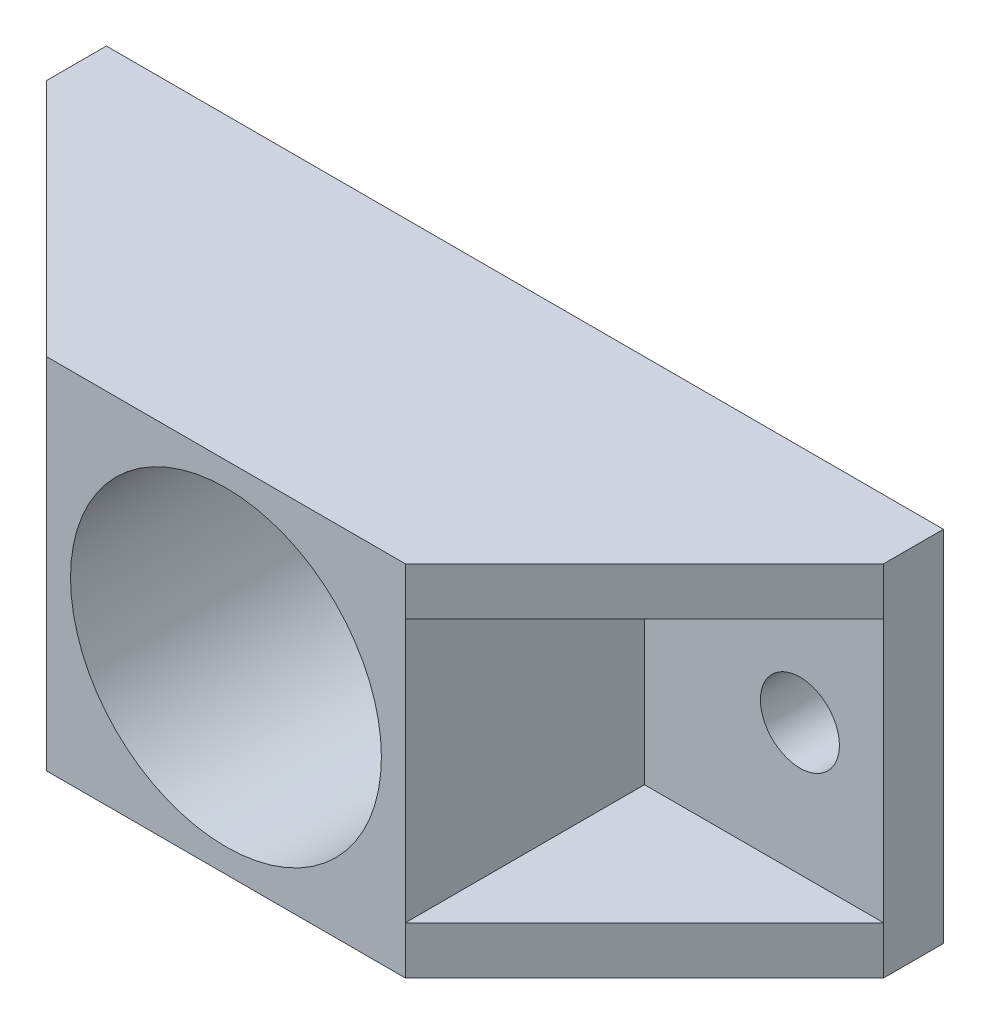
from build123d import *

# Parameters (mm, degrees)
SKETCH_1_W          = 70
SKETCH_1_H          = 30
SKETCH_1_R          = 3.3
EXTRUDE_1_DEPTH     = 5
SKETCH_2_W          = 30
SKETCH_2_H          = 30
EXTRUDE_2_DEPTH     = 20
SKETCH_3_R          = 13
CUT_EXTRUDE_1_DEPTH = 26
EXTRUDE_3_DEPTH     = 4


with BuildPart() as part:
    # 草图1 → 凸台-拉伸1 (new body)
    with BuildSketch(Plane.XY):
        Rectangle(SKETCH_1_W, SKETCH_1_H)
        with Locations((-28, 0)):
            Circle(SKETCH_1_R, mode=Mode.SUBTRACT)
        with Locations((28, 0)):
            Circle(SKETCH_1_R, mode=Mode.SUBTRACT)
    extrude(amount=EXTRUDE_1_DEPTH)

    # 草图2 → 凸台-拉伸2 (add)
    with BuildSketch(Plane.XY.offset(5)):
        Rectangle(SKETCH_2_W, SKETCH_2_H)
    extrude(amount=EXTRUDE_2_DEPTH)

    # 草图3 → 切除-拉伸1 (cut, through all)
    with BuildSketch(Plane.XY.offset(25)):
        Circle(SKETCH_3_R)
    extrude(amount=-CUT_EXTRUDE_1_DEPTH, mode=Mode.SUBTRACT)

    # 草图5 → 凸台-拉伸3 (add)
    with BuildSketch(Plane.XZ.offset(15)):
        Polygon((-35, 5), (-15, 25), (-15, 5), align=None)
        Polygon((15, 25), (35, 5), (15, 5), align=None)
    extrude_3 = extrude(amount=-EXTRUDE_3_DEPTH)

    # 镜向1: 凸台-拉伸3 across plane
    add(extrude_3.mirror(Plane.ZX))


solid = part.part
